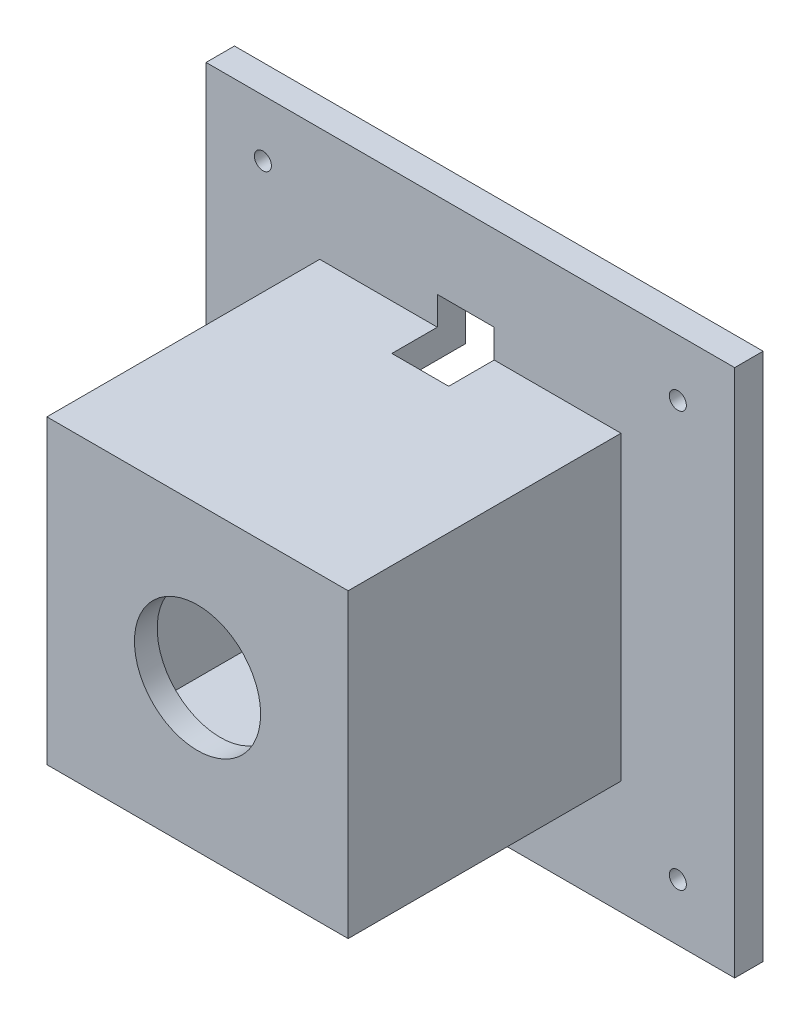
from build123d import *

# Parameters (mm, degrees)
ESQUISSE1_W             = 93
ESQUISSE1_H             = 93
BOSS_EXTRU_1_DEPTH      = 5
ESQUISSE2_W             = 53
ESQUISSE2_H             = 53
BOSS_EXTRU_2_DEPTH      = 48
ESQUISSE3_W             = 43
ESQUISSE3_H             = 43
ENL_V_MAT_EXTRU_1_DEPTH = 49
ENL_V_MAT_EXTRU_2_REACH = 55
ESQUISSE4_R             = 11.1
ENL_V_MAT_EXTRU_3_REACH = 7
ESQUISSE5_R             = 1.5
ESQUISSE7_W             = 10
ESQUISSE7_H             = 13
ENL_V_MAT_EXTRU_4_DEPTH = 10


with BuildPart() as part:
    # Esquisse1 → Boss.-Extru.1 (new body)
    with BuildSketch(Plane.XY):
        with Locations((25.019689463, -26.276315789)):
            Rectangle(ESQUISSE1_W, ESQUISSE1_H)
    extrude(amount=BOSS_EXTRU_1_DEPTH)

    # Esquisse2 → Boss.-Extru.2 (add)
    with BuildSketch(Plane.XY.offset(5)):
        with Locations((25.01969205, -26.276318376)):
            Rectangle(ESQUISSE2_W, ESQUISSE2_H)
    extrude(amount=BOSS_EXTRU_2_DEPTH)

    # Esquisse3 → Enlèv. mat.-Extru.1 (cut)
    with BuildSketch(Plane(origin=(0, 0, 0), x_dir=(-1, 0, 0), z_dir=(0, 0, -1))):
        with Locations((-25.019689463, -26.276315789)):
            Rectangle(ESQUISSE3_W, ESQUISSE3_H)
    extrude(amount=-ENL_V_MAT_EXTRU_1_DEPTH, mode=Mode.SUBTRACT)

    # Esquisse4 → Enlèv. mat.-Extru.2 (cut, up to next)
    with BuildSketch(Plane.XY.offset(53), mode=Mode.PRIVATE) as enl_v_mat_extru_2_sk1:
        with Locations((25.01969205, -26.276318376)):
            Circle(ESQUISSE4_R)
    enl_v_mat_extru_2_tool1 = extrude(enl_v_mat_extru_2_sk1.sketch, amount=-ENL_V_MAT_EXTRU_2_REACH, mode=Mode.PRIVATE) & part.part
    add(enl_v_mat_extru_2_tool1.solids().sort_by_distance((25.019692, -26.276318, 53))[0], mode=Mode.SUBTRACT)

    # Esquisse5 → Enlèv. mat.-Extru.3 (cut, up to next)
    with BuildSketch(Plane.XY.offset(5), mode=Mode.PRIVATE) as enl_v_mat_extru_3_sk1:
        with Locations((61.519689463, -62.776315789)):
            Circle(ESQUISSE5_R)
    enl_v_mat_extru_3_tool1 = extrude(enl_v_mat_extru_3_sk1.sketch, amount=-ENL_V_MAT_EXTRU_3_REACH, mode=Mode.PRIVATE) & part.part
    add(enl_v_mat_extru_3_tool1.solids().sort_by_distance((61.519689, -62.776316, 5))[0], mode=Mode.SUBTRACT)
    # Esquisse5 → Enlèv. mat.-Extru.3 (cut, up to next)
    with BuildSketch(Plane.XY.offset(5), mode=Mode.PRIVATE) as enl_v_mat_extru_3_sk2:
        with Locations((-11.480310537, -62.776315789)):
            Circle(ESQUISSE5_R)
    enl_v_mat_extru_3_tool2 = extrude(enl_v_mat_extru_3_sk2.sketch, amount=-ENL_V_MAT_EXTRU_3_REACH, mode=Mode.PRIVATE) & part.part
    add(enl_v_mat_extru_3_tool2.solids().sort_by_distance((-11.480311, -62.776316, 5))[0], mode=Mode.SUBTRACT)
    # Esquisse5 → Enlèv. mat.-Extru.3 (cut, up to next)
    with BuildSketch(Plane.XY.offset(5), mode=Mode.PRIVATE) as enl_v_mat_extru_3_sk3:
        with Locations((-11.480310537, 10.223684211)):
            Circle(ESQUISSE5_R)
    enl_v_mat_extru_3_tool3 = extrude(enl_v_mat_extru_3_sk3.sketch, amount=-ENL_V_MAT_EXTRU_3_REACH, mode=Mode.PRIVATE) & part.part
    add(enl_v_mat_extru_3_tool3.solids().sort_by_distance((-11.480311, 10.223684, 5))[0], mode=Mode.SUBTRACT)
    # Esquisse5 → Enlèv. mat.-Extru.3 (cut, up to next)
    with BuildSketch(Plane.XY.offset(5), mode=Mode.PRIVATE) as enl_v_mat_extru_3_sk4:
        with Locations((61.519689463, 10.223684211)):
            Circle(ESQUISSE5_R)
    enl_v_mat_extru_3_tool4 = extrude(enl_v_mat_extru_3_sk4.sketch, amount=-ENL_V_MAT_EXTRU_3_REACH, mode=Mode.PRIVATE) & part.part
    add(enl_v_mat_extru_3_tool4.solids().sort_by_distance((61.519689, 10.223684, 5))[0], mode=Mode.SUBTRACT)

    # Esquisse7 → Enlèv. mat.-Extru.4 (cut)
    with BuildSketch(Plane.XZ.offset(4.776315789)):
        with Locations((24.207318305, 6.5)):
            Rectangle(ESQUISSE7_W, ESQUISSE7_H)
    extrude(amount=-ENL_V_MAT_EXTRU_4_DEPTH, mode=Mode.SUBTRACT)


solid = part.part
